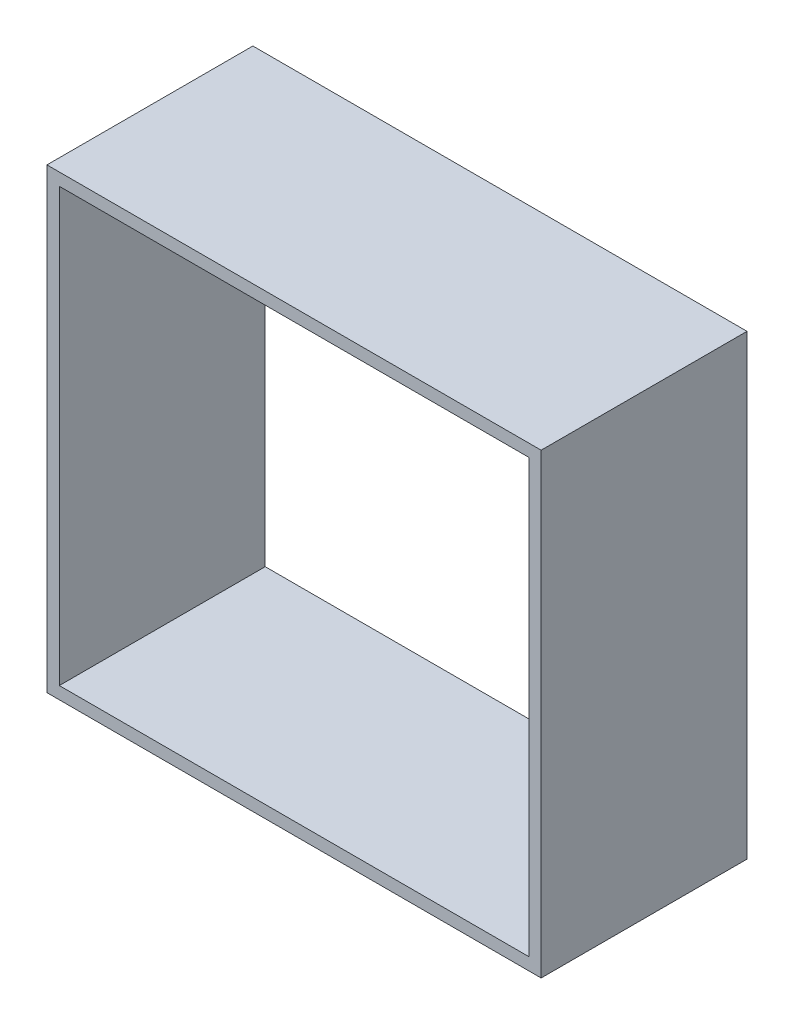
from build123d import *

# Parameters (mm, degrees)
SKETCH2_W           = 60
SKETCH2_H           = 55.5
SKETCH2_W_2         = 57
SKETCH2_H_2         = 52.5
BOSS_EXTRUDE1_DEPTH = 25


with BuildPart() as part:
    # Sketch2 → Boss-Extrude1 (new body)
    with BuildSketch(Plane.XY):
        with Locations((-60.989583333, 27.75)):
            Rectangle(SKETCH2_W, SKETCH2_H)
        with Locations((-60.989583333, 27.75)):
            Rectangle(SKETCH2_W_2, SKETCH2_H_2, mode=Mode.SUBTRACT)
    extrude(amount=BOSS_EXTRUDE1_DEPTH)


solid = part.part
